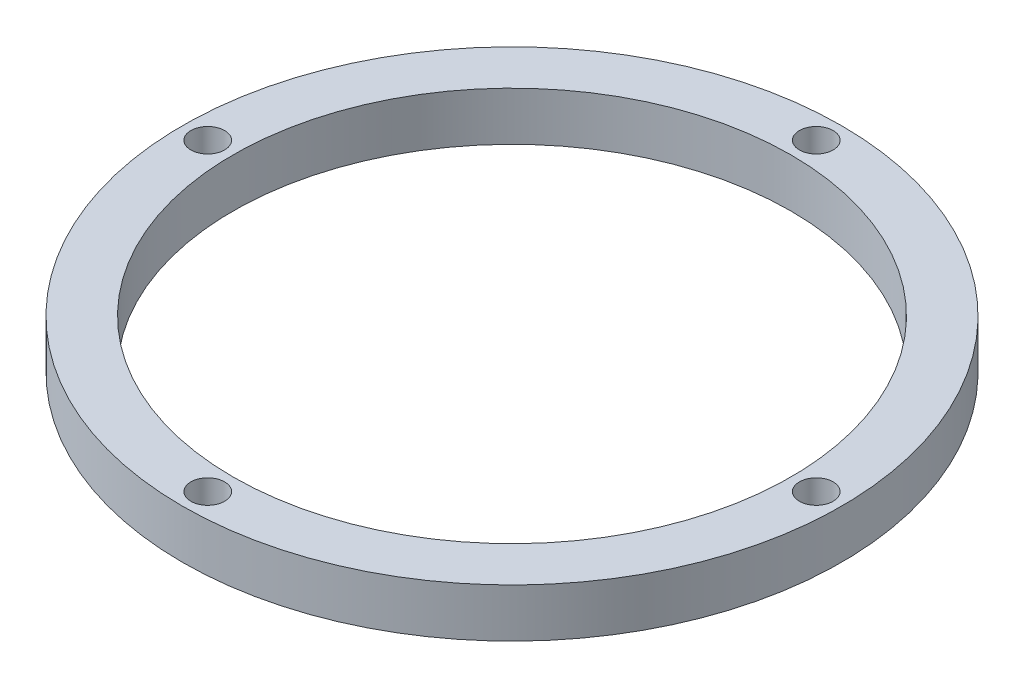
from build123d import *

# Parameters (mm, degrees)
SKETCH2_R           = 32.258
SKETCH2_R_2         = 27.305
BOSS_EXTRUDE1_DEPTH = 4.7625
SKETCH3_R           = 1.651
CUT_EXTRUDE1_DEPTH  = 5.7625
CIRPATTERN1_COUNT   = 4


with BuildPart() as part:
    # Sketch2 → Boss-Extrude1 (new body)
    with BuildSketch(Plane(origin=(0, 0, 0), x_dir=(1, 0, 0), z_dir=(0, 1, 0))):
        Circle(SKETCH2_R)
        Circle(SKETCH2_R_2, mode=Mode.SUBTRACT)
    extrude(amount=BOSS_EXTRUDE1_DEPTH)

    # Sketch3 → Cut-Extrude1 (cut, through all)
    with BuildSketch(Plane(origin=(0, 4.7625, 0), x_dir=(1, 0, 0), z_dir=(0, 1, 0))):
        with Locations((0, 29.7815)):
            Circle(SKETCH3_R)
    cut_extrude1 = extrude(amount=-CUT_EXTRUDE1_DEPTH, mode=Mode.SUBTRACT)

    # CirPattern1: Cut-Extrude1 ×4 about axis
    cirpattern1_axis = Axis((0, 0, 0), (0, 1, 0))
    for i in range(1, CIRPATTERN1_COUNT):
        add(cut_extrude1.rotate(cirpattern1_axis, i * 360 / CIRPATTERN1_COUNT), mode=Mode.SUBTRACT)


solid = part.part
